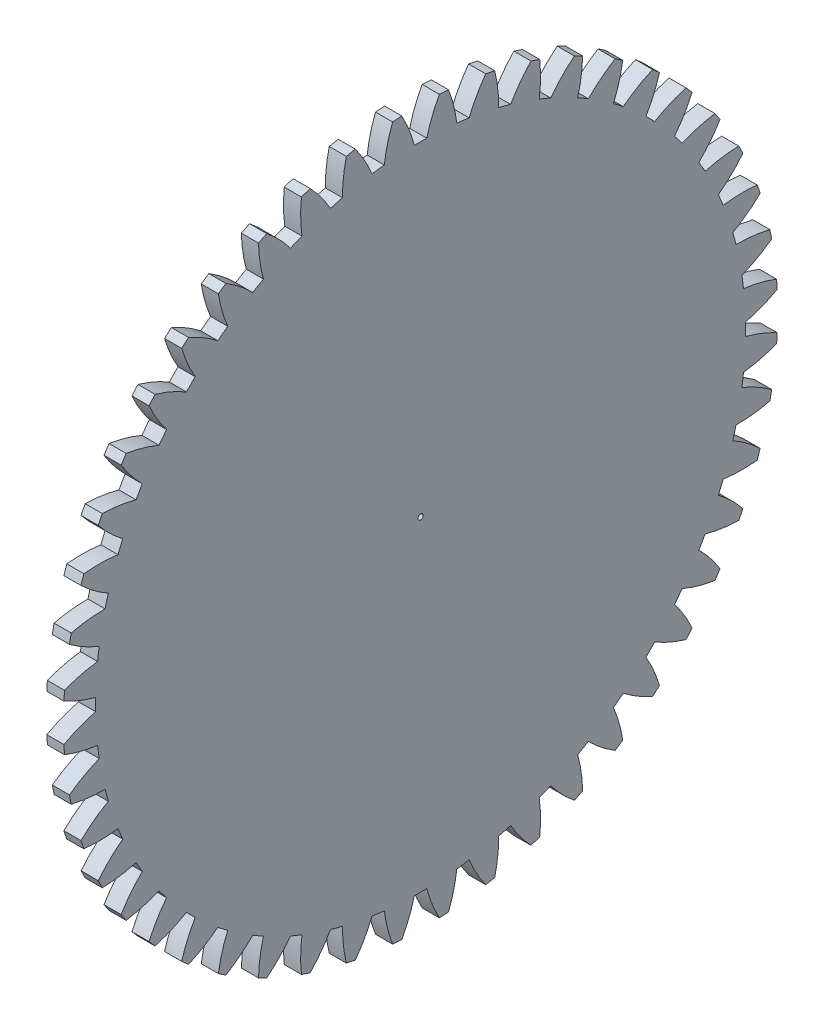
from build123d import *

# Parameters (mm, degrees)
BASPROSKE_W     = 3
BASPROSKE_H     = 62.5
TOOTHCUT_DEPTH  = 89.439244682
TEETHCUTS_COUNT = 48
TEETHCUTS_ANGLE = 352.5
BORSKE_R        = 0.45
BORE_DEPTH      = 50.0000508


with BuildPart() as part:
    # BasProSke → Base-Revolve (revolve)
    with BuildSketch(Plane(origin=(0, 0, 0), x_dir=(1, 0, 0), z_dir=(0, 1, 0)), mode=Mode.PRIVATE) as base_revolve_sk:
        with Locations((1.5, 31.25)):
            Rectangle(BASPROSKE_W, BASPROSKE_H)
    revolve(base_revolve_sk.sketch.rotate(Axis((-10, 0, 0), (1, 0, 0)), 180), axis=Axis((-10, 0, 0), (1, 0, 0)))

    # TooCutSke → ToothCut (cut, through all)
    with BuildSketch(Plane(origin=(0, 0, 0), x_dir=(0, 0, -1), z_dir=(1, 0, 0))):
        with BuildLine():
            ThreePointArc((1.085909819, 56.863632278), (0, 56.874), (-1.085909819, 56.863632278))
            ThreePointArc((-1.085909819, 56.863632278), (-2.017650528, 59.720377219), (-3.299057521, 62.438304466))
            ThreePointArc((-3.299057521, 62.438304466), (0, 62.5254), (3.299057521, 62.438304466))
            ThreePointArc((3.299057521, 62.438304466), (2.017650528, 59.720377219), (1.085909819, 56.863632278))
        make_face()
    toothcut = extrude(amount=TOOTHCUT_DEPTH, mode=Mode.SUBTRACT)

    # TeethCuts: ToothCut ×48 about axis
    teethcuts_axis = Axis((-10, 0, 0), (1, 0, 0))
    for i in range(1, TEETHCUTS_COUNT):
        add(toothcut.rotate(teethcuts_axis, i * TEETHCUTS_ANGLE / (TEETHCUTS_COUNT - 1)), mode=Mode.SUBTRACT)

    # BorSke → Bore (cut, symmetric)
    with BuildSketch(Plane(origin=(0, 0, 0), x_dir=(0, 0, -1), z_dir=(1, 0, 0))):
        with Locations(Location((0, 0, 0), (0, 0, 180))):
            Circle(BORSKE_R)
    extrude(amount=BORE_DEPTH, both=True, mode=Mode.SUBTRACT)


solid = part.part
